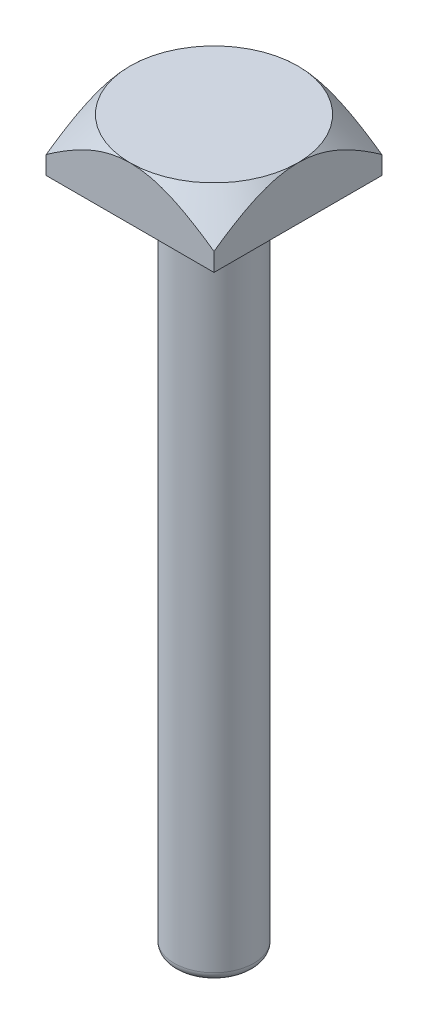
from build123d import *

# Parameters (mm, degrees)
SKETCH1_W           = 4.5
SKETCH1_H           = 76
SKETCH2_W           = 19
SKETCH2_H           = 19
BOSS_EXTRUDE1_DEPTH = 6
FILLET4_R           = 1
SKETCH7_OUTSIDE_W   = 58.258
SKETCH7_OUTSIDE_H   = 58.258
SKETCH7_OUTSIDE_R   = 9.5
CUT_EXTRUDE1_DEPTH  = 10
CUT_EXTRUDE1_DRAFT  = -45


with BuildPart() as part:
    # Sketch1 → Revolve1 (revolve)
    with BuildSketch(Plane.XY):
        with Locations((2.25, -38)):
            Rectangle(SKETCH1_W, SKETCH1_H)
    revolve(axis=Axis((4.5, 0, 0), (0, -1, 0)))

    # Sketch2 → Boss-Extrude1 (add)
    with BuildSketch(Plane(origin=(0, 0, 0), x_dir=(1, 0, 0), z_dir=(0, 1, 0))):
        with Locations((4.5, 0)):
            Rectangle(SKETCH2_W, SKETCH2_H)
    extrude(amount=BOSS_EXTRUDE1_DEPTH)

    # Fillet4
    fillet4_edges = [part.edges().sort_by_distance(p)[0] for p in [
        (9, -76, 0),
    ]]
    fillet(fillet4_edges, radius=FILLET4_R)


with BuildPart() as cut_extrude1_tool:
    # Sketch7 outside → Cut-Extrude1 (with draft: the straight prism first)
    with BuildSketch(Plane(origin=(0, 6, 0), x_dir=(1, 0, 0), z_dir=(0, 1, 0))):
        with Locations((4.5, 0)):
            Rectangle(SKETCH7_OUTSIDE_W, SKETCH7_OUTSIDE_H)
        with Locations((4.5, 0)):
            Circle(SKETCH7_OUTSIDE_R, mode=Mode.SUBTRACT)
    extrude(amount=-CUT_EXTRUDE1_DEPTH)
    # Cut-Extrude1: the draft: its side faces are tilted about the plane it starts from
    cut_extrude1_sides = [cut_extrude1_tool.faces().sort_by_distance(p)[0] for p in [
        (4.5, 1, 29.129),
        (33.629, 1, 0),
        (4.5, 1, -29.129),
        (-24.629, 1, 0),
        (-5, 1, 0),
    ]]
    draft(cut_extrude1_sides, Plane(origin=(0, 6, 0), x_dir=(1, 0, 0), z_dir=(0, 1, 0)), CUT_EXTRUDE1_DRAFT)


with BuildPart() as part_1:
    add(part.part)

    # Cut-Extrude1: cut by cut_extrude1_tool
    add(cut_extrude1_tool.part, mode=Mode.SUBTRACT)


solid = part_1.part
